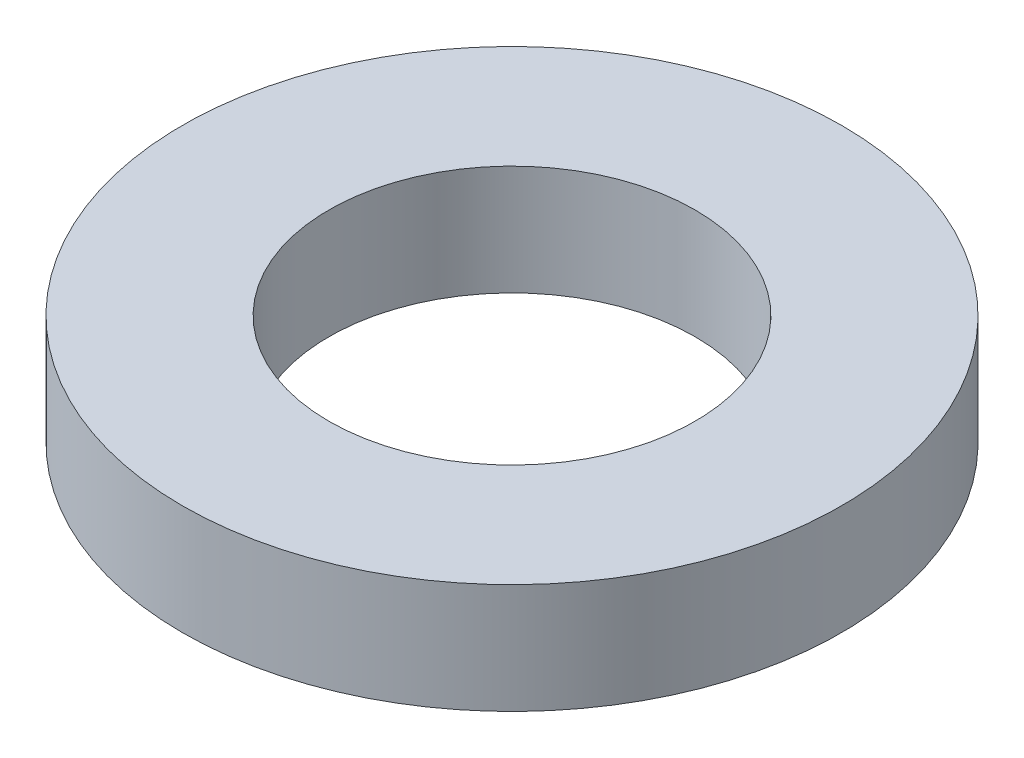
from build123d import *

# Parameters (mm, degrees)
SKETCH1_R           = 4.5
SKETCH1_R_2         = 2.5
BOSS_EXTRUDE1_DEPTH = 1.5


with BuildPart() as part:
    # Sketch1 → Boss-Extrude1 (new body)
    with BuildSketch(Plane(origin=(0, 0, 0), x_dir=(1, 0, 0), z_dir=(0, 1, 0))):
        Circle(SKETCH1_R)
        Circle(SKETCH1_R_2, mode=Mode.SUBTRACT)
    extrude(amount=BOSS_EXTRUDE1_DEPTH)


solid = part.part
